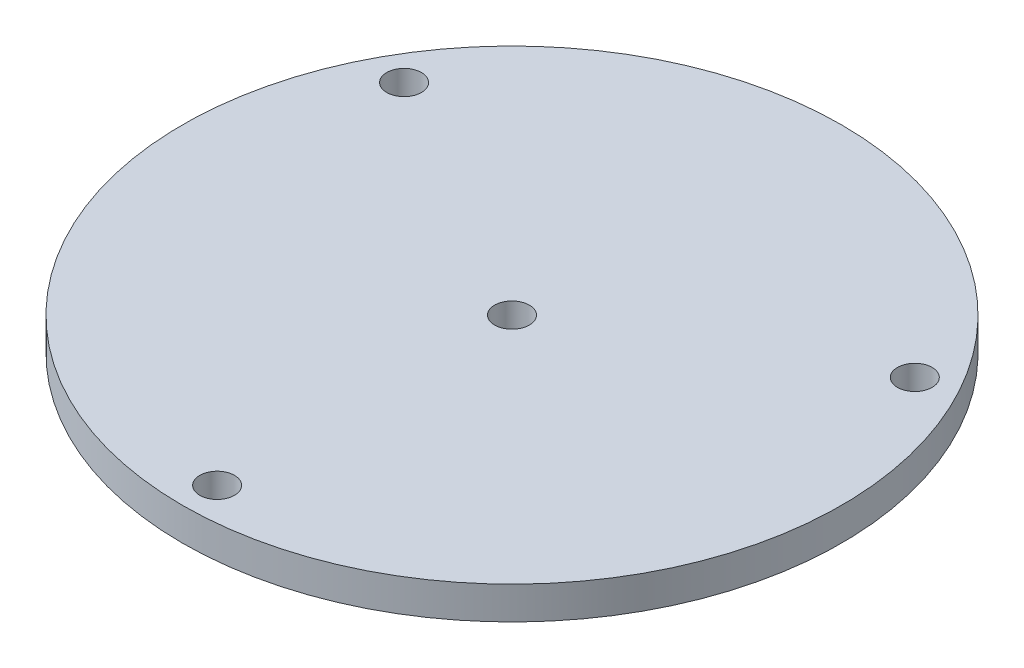
from build123d import *

# Parameters (mm, degrees)
SKETCH1_R           = 60.3504
SKETCH1_R_2         = 3.175
BOSS_EXTRUDE1_DEPTH = 6


with BuildPart() as part:
    # Sketch1 → Boss-Extrude1 (new body)
    with BuildSketch(Plane(origin=(0, 0, 0), x_dir=(1, 0, 0), z_dir=(0, 1, 0))):
        Circle(SKETCH1_R)
        Circle(SKETCH1_R_2, mode=Mode.SUBTRACT)
        with Locations((0, -54.0004)):
            Circle(SKETCH1_R_2, mode=Mode.SUBTRACT)
        with Locations((-46.765718215, 27.0002)):
            Circle(SKETCH1_R_2, mode=Mode.SUBTRACT)
        with Locations((46.765718215, 27.0002)):
            Circle(SKETCH1_R_2, mode=Mode.SUBTRACT)
    extrude(amount=BOSS_EXTRUDE1_DEPTH)


solid = part.part
